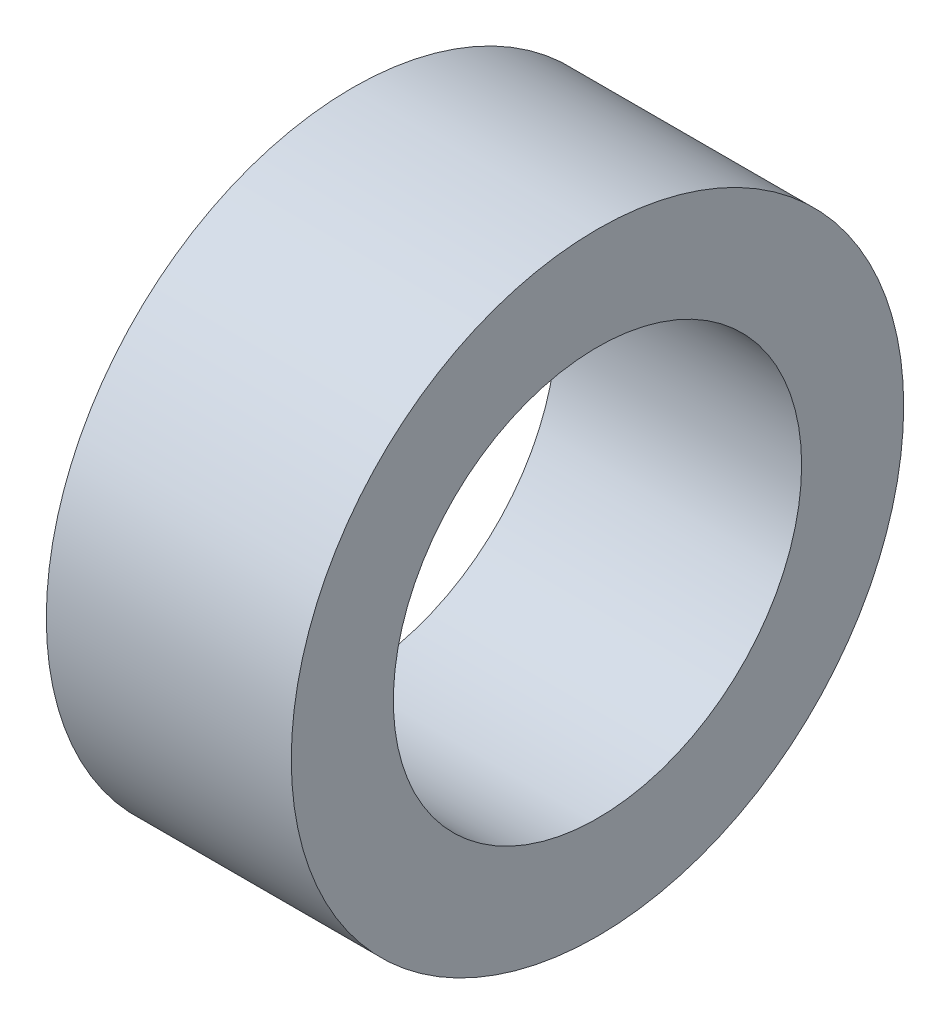
from build123d import *

# Parameters (mm, degrees)
SKETCH_1_R      = 15
SKETCH_1_R_2    = 10
EXTRUDE_1_DEPTH = 12


with BuildPart() as part:
    # 草图1 → 凸台-拉伸1 (new body)
    with BuildSketch(Plane(origin=(0, 0, 0), x_dir=(0, 0, -1), z_dir=(1, 0, 0))):
        Circle(SKETCH_1_R)
        Circle(SKETCH_1_R_2, mode=Mode.SUBTRACT)
    extrude(amount=EXTRUDE_1_DEPTH)


solid = part.part
